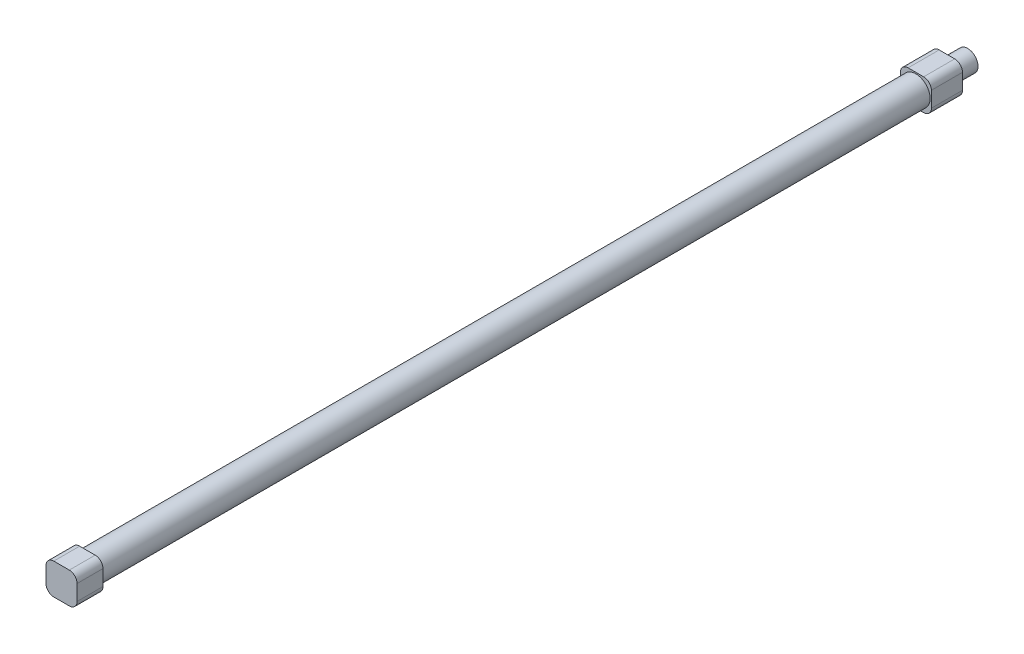
from build123d import *

# Parameters (mm, degrees)
SKETCH_1_R          = 5.5
SKETCH_1_R_2        = 5
EXTRUDE_1_DEPTH     = 320
EXTRUDE_2_DEPTH     = 10
EXTRUDE_3_DEPTH     = 12
SKETCH_4_R          = 4
EXTRUDE_4_DEPTH     = 8
SKETCH_5_R          = 2
CUT_EXTRUDE_1_DEPTH = 38
SKETCH_6_R          = 2
CUT_EXTRUDE_3_DEPTH = 3


with BuildPart() as part:
    # 草图1 → 凸台-拉伸1 (new body)
    with BuildSketch(Plane.XY):
        Circle(SKETCH_1_R)
        Circle(SKETCH_1_R_2, mode=Mode.SUBTRACT)
    extrude(amount=EXTRUDE_1_DEPTH)

    # 草图2 → 凸台-拉伸2 (add)
    with BuildSketch(Plane.XY.offset(320)):
        with BuildLine():
            Line((-3, -6), (3, -6))
            ThreePointArc((3, -6), (5.121320344, -5.121320344), (6, -3))
            Line((6, -3), (6, 3))
            ThreePointArc((6, 3), (5.121320344, 5.121320344), (3, 6))
            Line((3, 6), (-3, 6))
            ThreePointArc((-3, 6), (-5.121320344, 5.121320344), (-6, 3))
            Line((-6, 3), (-6, -3))
            ThreePointArc((-6, -3), (-5.121320344, -5.121320344), (-3, -6))
        make_face()
    extrude(amount=EXTRUDE_2_DEPTH)

    # 草图3 → 凸台-拉伸3 (add)
    with BuildSketch(Plane(origin=(0, 0, 0), x_dir=(-1, 0, 0), z_dir=(0, 0, -1))):
        with BuildLine():
            Line((-3, -6), (3, -6))
            ThreePointArc((3, -6), (5.121320344, -5.121320344), (6, -3))
            Line((6, -3), (6, 3))
            ThreePointArc((6, 3), (5.121320344, 5.121320344), (3, 6))
            Line((3, 6), (-3, 6))
            ThreePointArc((-3, 6), (-5.121320344, 5.121320344), (-6, 3))
            Line((-6, 3), (-6, -3))
            ThreePointArc((-6, -3), (-5.121320344, -5.121320344), (-3, -6))
        make_face()
    extrude(amount=EXTRUDE_3_DEPTH)

    # 草图4 → 凸台-拉伸4 (add)
    with BuildSketch(Plane(origin=(0, 0, -12), x_dir=(-1, 0, 0), z_dir=(0, 0, -1))):
        Circle(SKETCH_4_R)
    extrude(amount=EXTRUDE_4_DEPTH)

    # 草图5 → 切除-拉伸1 (cut)
    with BuildSketch(Plane(origin=(0, 0, -20), x_dir=(-1, 0, 0), z_dir=(0, 0, -1))):
        Circle(SKETCH_5_R)
    extrude(amount=-CUT_EXTRUDE_1_DEPTH, mode=Mode.SUBTRACT)

    # 草图6 → 切除-拉伸3 (cut)
    with BuildSketch(Plane.ZY.offset(6)):
        with Locations((-4, 0)):
            Circle(SKETCH_6_R)
        with Locations((324, 0)):
            Circle(SKETCH_6_R)
    extrude(amount=-CUT_EXTRUDE_3_DEPTH, mode=Mode.SUBTRACT)


solid = part.part
